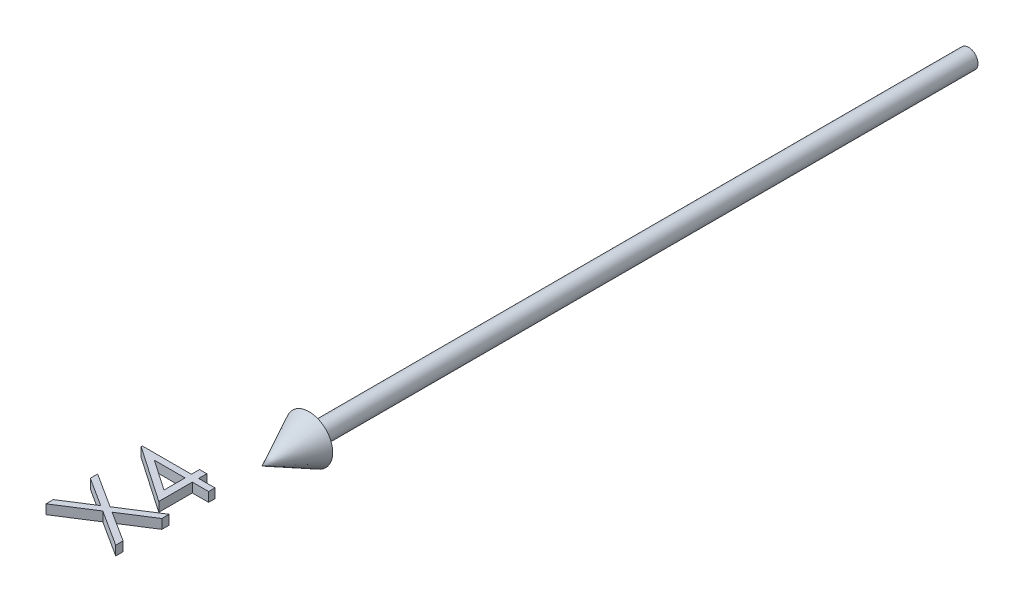
from build123d import *

# Parameters (mm, degrees)
BOSS_EXTRUDE1_DEPTH        = 1
BOSS_EXTRUDE1_DEPTH_BACK   = 1
BOSS_EXTRUDE1_2_DEPTH      = 1
BOSS_EXTRUDE1_2_DEPTH_BACK = 1


with BuildPart() as part:
    # Sketch2 → Revolve1 (revolve)
    with BuildSketch(Plane(origin=(0, 0, 0), x_dir=(1, 0, 0), z_dir=(0, 1, 0))):
        Polygon((0, -150), (5, -140), (2, -140), (2, 0), (0, 0), align=None)
    revolve(axis=Axis((0, 0, -41.949952025), (0, 0, 1)))


with BuildPart() as body_2:
    # Sketch3 → Boss-Extrude1 (new, two sides: drawn at the far end of the back side and taken through both)
    with BuildSketch(Plane(origin=(0, 0, 0), x_dir=(1, 0, 0), z_dir=(0, 1, 0)).offset(-BOSS_EXTRUDE1_DEPTH_BACK)):
        Polygon((-15.384615385, -160.2734375), (-15.384615385, -160), (-5, -160), (-5, -158.269230769), (-3.461538462, -158.269230769), (-3.461538462, -160), (0, -160), (0, -161.346153846), (-3.461538462, -161.346153846), (-3.461538462, -168.461538462), align=None)
        Polygon((-5, -161.346153846), (-11.514423077, -161.346153846), (-5, -165.817307692), align=None, mode=Mode.SUBTRACT)
    extrude(amount=BOSS_EXTRUDE1_DEPTH + BOSS_EXTRUDE1_DEPTH_BACK)


with BuildPart() as body_3:
    # Sketch3 → Boss-Extrude1 2 (new, two sides: drawn at the far end of the back side and taken through both)
    with BuildSketch(Plane(origin=(0, 0, 0), x_dir=(1, 0, 0), z_dir=(0, 1, 0)).offset(-BOSS_EXTRUDE1_2_DEPTH_BACK)):
        Polygon((-15, -180.865384615), (-15, -179.311899038), (-8.864182692, -175.384615385), (-15, -171.457331731), (-15, -169.903846154), (-7.650240385, -174.606370192), (0, -169.711538462), (0, -171.265024038), (-6.436298077, -175.384615385), (0, -179.504206731), (0, -181.057692308), (-7.650240385, -176.159855769), align=None)
    extrude(amount=BOSS_EXTRUDE1_2_DEPTH + BOSS_EXTRUDE1_2_DEPTH_BACK)


solid = Compound([part.part, body_2.part, body_3.part])
